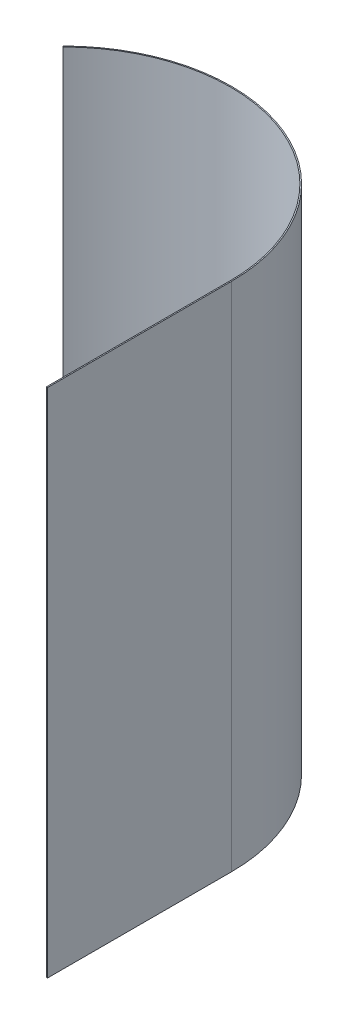
from build123d import *

# Parameters (mm, degrees)
SALIENTE_EXTRUIR1_DEPTH = 500


with BuildPart() as part:
    # Croquis3 → Saliente-Extruir1 (new body)
    with BuildSketch(Plane(origin=(0, 0, 0), x_dir=(1, 0, 0), z_dir=(0, 1, 0))):
        with BuildLine():
            Line((31.15, 127.741818938), (31.15, -52.258181062))
            Line((31.15, -52.258181062), (30, -52.258181062))
            Line((30, -52.258181062), (30, 127.741818938))
            ThreePointArc((30, 127.741818938), (-71.147319607, 279.11948034), (-249.709446097, 243.601265035))
            Line((-249.709446097, 243.601265035), (-250.522618896, 244.414437834))
            ThreePointArc((-250.522618896, 244.414437834), (-70.70723366, 280.181941802), (31.15, 127.741818938))
        make_face()
    extrude(amount=SALIENTE_EXTRUIR1_DEPTH)


solid = part.part
